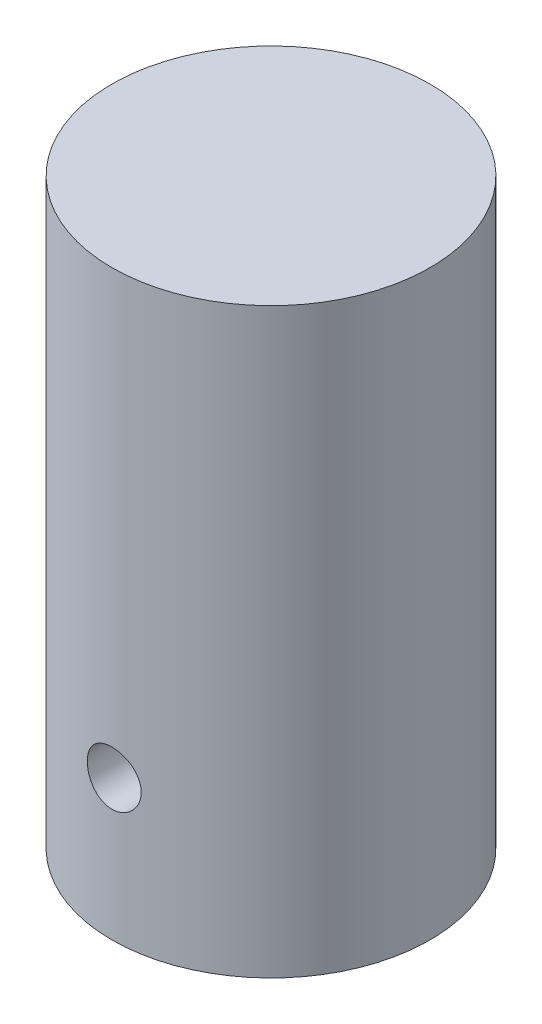
from build123d import *

# Parameters (mm, degrees)
SKETCH1_R           = 37.465
BOSS_EXTRUDE1_DEPTH = 137.16
SKETCH3_R           = 6.35
CUT_EXTRUDE1_DEPTH  = 19.05
SKETCH4_R           = 6.35
CUT_EXTRUDE2_DEPTH  = 19.05


with BuildPart() as part:
    # Sketch1 → Boss-Extrude1 (new body)
    with BuildSketch(Plane(origin=(0, 0, 0), x_dir=(1, 0, 0), z_dir=(0, 1, 0))):
        Circle(SKETCH1_R)
    extrude(amount=BOSS_EXTRUDE1_DEPTH)

    # Sketch3 → Cut-Extrude1 (cut)
    with BuildSketch(Plane.XY.offset(37.465)):
        with Locations((0, 33.02)):
            Circle(SKETCH3_R)
    extrude(amount=-CUT_EXTRUDE1_DEPTH, mode=Mode.SUBTRACT)

    # Sketch4 → Cut-Extrude2 (cut)
    with BuildSketch(Plane.XZ):
        Circle(SKETCH4_R)
    extrude(amount=-CUT_EXTRUDE2_DEPTH, mode=Mode.SUBTRACT)


solid = part.part
